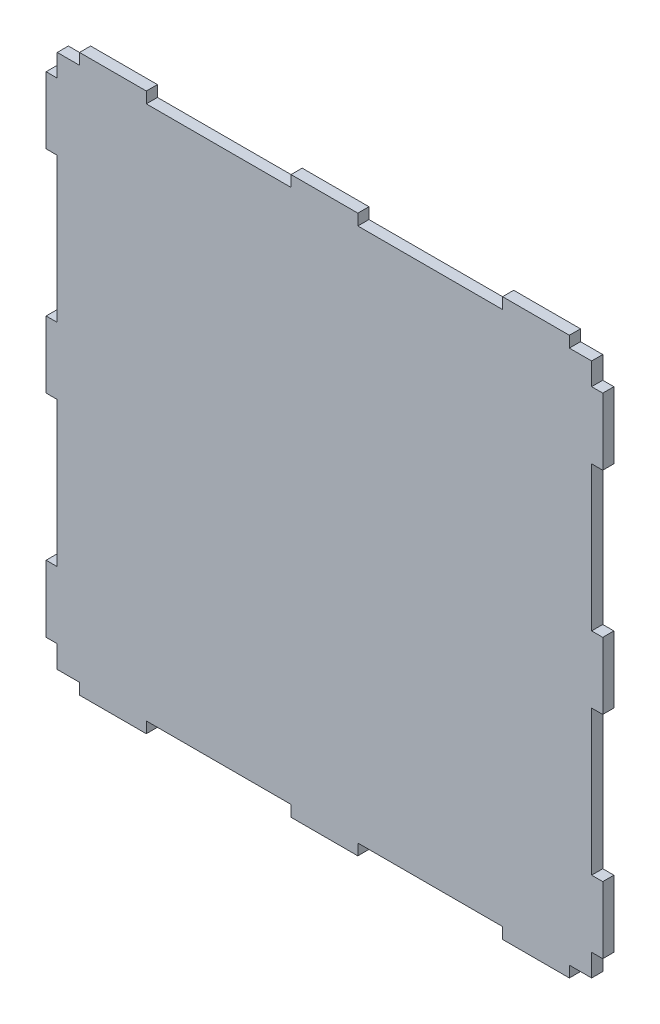
from build123d import *

# Parameters (mm, degrees)
SKETCH1_W           = 240
SKETCH1_H           = 240
SKETCH1_W_2         = 30
SKETCH1_H_2         = 5
SKETCH1_W_3         = 5
SKETCH1_H_3         = 30
BOSS_EXTRUDE1_DEPTH = 5


with BuildPart() as part:
    # Sketch1 → Boss-Extrude1 (new body)
    with BuildSketch(Plane.XY):
        Rectangle(SKETCH1_W, SKETCH1_H)
        with Locations((0, 122.5)):
            Rectangle(SKETCH1_W_2, SKETCH1_H_2)
        with Locations((95, 122.5)):
            Rectangle(SKETCH1_W_2, SKETCH1_H_2)
        with Locations((-122.5, 95)):
            Rectangle(SKETCH1_W_3, SKETCH1_H_3)
        with Locations((-122.5, 0)):
            Rectangle(SKETCH1_W_3, SKETCH1_H_3)
        with Locations((-122.5, -95)):
            Rectangle(SKETCH1_W_3, SKETCH1_H_3)
        with Locations((-95, -122.5)):
            Rectangle(SKETCH1_W_2, SKETCH1_H_2)
        with Locations((0, -122.5)):
            Rectangle(SKETCH1_W_2, SKETCH1_H_2)
        with Locations((95, -122.5)):
            Rectangle(SKETCH1_W_2, SKETCH1_H_2)
        with Locations((122.5, -95)):
            Rectangle(SKETCH1_W_3, SKETCH1_H_3)
        with Locations((122.5, 0)):
            Rectangle(SKETCH1_W_3, SKETCH1_H_3)
        with Locations((122.5, 95)):
            Rectangle(SKETCH1_W_3, SKETCH1_H_3)
        with Locations((-95, 122.5)):
            Rectangle(SKETCH1_W_2, SKETCH1_H_2)
    extrude(amount=BOSS_EXTRUDE1_DEPTH)


solid = part.part
